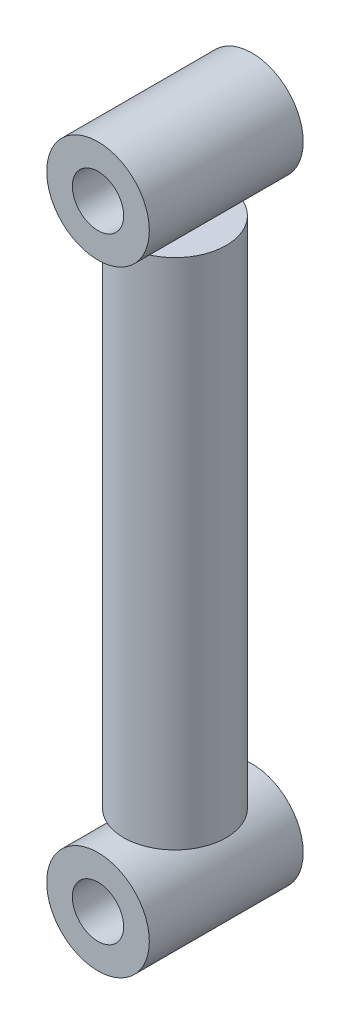
from build123d import *

# Parameters (mm, degrees)
SKETCH2_R           = 25.4
BOSS_EXTRUDE1_DEPTH = 254
SKETCH3_R           = 25.4
BOSS_EXTRUDE2_DEPTH = 38.1
SKETCH4_R           = 25.4
BOSS_EXTRUDE3_DEPTH = 38.1
SKETCH5_R           = 12.7
CUT_EXTRUDE1_DEPTH  = 77.2
SKETCH6_R           = 12.7
CUT_EXTRUDE2_DEPTH  = 77.2


with BuildPart() as part:
    # Sketch2 → Boss-Extrude1 (new body)
    with BuildSketch(Plane(origin=(0, 0, 0), x_dir=(1, 0, 0), z_dir=(0, 1, 0))):
        Circle(SKETCH2_R)
    extrude(amount=BOSS_EXTRUDE1_DEPTH)


with BuildPart() as body_2:
    # Sketch3 → Boss-Extrude2 (new body, symmetric)
    with BuildSketch(Plane.XY):
        with Locations((0, 279.4)):
            Circle(SKETCH3_R)
    extrude(amount=BOSS_EXTRUDE2_DEPTH, both=True)

    # Sketch5 → Cut-Extrude1 (cut, through all)
    with BuildSketch(Plane.XY.offset(38.1)):
        with Locations((0, 279.4)):
            Circle(SKETCH5_R)
    extrude(amount=-CUT_EXTRUDE1_DEPTH, mode=Mode.SUBTRACT)


with BuildPart() as body_3:
    # Sketch4 → Boss-Extrude3 (new body, symmetric)
    with BuildSketch(Plane.XY):
        with Locations((0, -25.4)):
            Circle(SKETCH4_R)
    extrude(amount=BOSS_EXTRUDE3_DEPTH, both=True)

    # Sketch6 → Cut-Extrude2 (cut, through all)
    with BuildSketch(Plane.XY.offset(38.1)):
        with Locations((0, -25.4)):
            Circle(SKETCH6_R)
    extrude(amount=-CUT_EXTRUDE2_DEPTH, mode=Mode.SUBTRACT)


solid = Compound([part.part, body_2.part, body_3.part])
